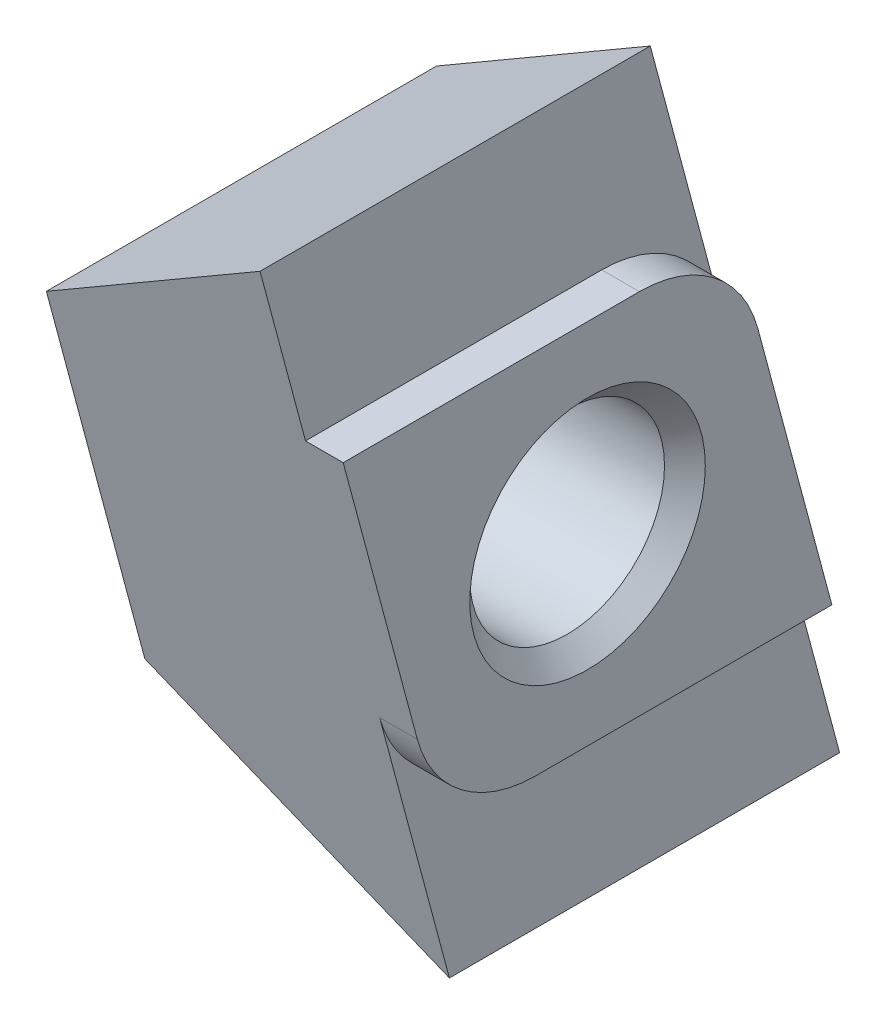
from build123d import *

# Parameters (mm, degrees)
EXTRUDE1_DEPTH = 0.8
EXTRUDE2_DEPTH = 5.5
DRAFT1_ANGLE   = -33.206570315
DRAFT2_ANGLE   = -33.206570315
HOLEWZD1_D     = 4.134
CHAMFER1_SIZE  = 0.433


with BuildPart() as part:
    # Sketch1 → Extrude1 (new body)
    with BuildSketch(Plane(origin=(0, 0, 0), x_dir=(0, 0, -1), z_dir=(1, 0, 0))):
        with BuildLine():
            Line((1.101052702, 3.9), (-5.186106572, 3.9))
            Line((-5.186106572, 3.9), (-3.612459851, -1.972929517))
            ThreePointArc((-3.612459851, -1.972929517), (-2.683832418, -3.362718685), (-1.101052702, -3.9))
            Line((-1.101052702, -3.9), (5.186106572, -3.9))
            Line((5.186106572, -3.9), (3.612459851, 1.972929517))
            ThreePointArc((3.612459851, 1.972929517), (2.683832418, 3.362718685), (1.101052702, 3.9))
        make_face()
    extrude(amount=-EXTRUDE1_DEPTH)

    # Sketch2 → Extrude2 (add)
    with BuildSketch(Plane.ZY.offset(0.8)):
        with BuildLine():
            Line((2.131485778, -7.5), (-6.150723665, -7.5))
            add(Edge.make_bspline(
                [(-2.131485778, 7.5), (-3.471231741, 2.5), (-4.810977703, -2.5), (-6.150723665, -7.5)],
                knots=[0, 0, 0, 0, 1, 1, 1, 1], degree=3))
            Line((-2.131485778, 7.5), (6.150723665, 7.5))
            add(Edge.make_bspline(
                [(2.131485778, -7.5), (3.471231741, -2.5), (4.810977703, 2.5), (6.150723665, 7.5)],
                knots=[0, 0, 0, 0, 1, 1, 1, 1], degree=3))
        make_face()
    extrude(amount=EXTRUDE2_DEPTH)

    # Draft1
    draft1_faces = [part.faces().sort_by_distance(p)[0] for p in [
        (-3.55, 7.5, 2.009618943),
    ]]
    draft(draft1_faces, Plane(origin=(-0.8, 0, 4.141104722), x_dir=(0, 0, 1), z_dir=(1, 0, 0)), DRAFT1_ANGLE)

    # Draft2
    draft2_faces = [part.faces().sort_by_distance(p)[0] for p in [
        (-3.55, -7.5, -2.009618943),
    ]]
    draft(draft2_faces, Plane(origin=(-0.8, 0, 4.141104722), x_dir=(0, 0, 1), z_dir=(1, 0, 0)), DRAFT2_ANGLE)

    # HoleWzd1 (through all)
    with Locations(Plane.ZY.offset(6.3)):
        with Locations((0, 0)):
            Hole(HOLEWZD1_D / 2)

    # Chamfer1
    chamfer1_edges = [part.edges().sort_by_distance(p)[0] for p in [
        (0, 0, 2.067),
        (-6.3, 0, 2.067),
    ]]
    chamfer(chamfer1_edges, length=CHAMFER1_SIZE)


solid = part.part
